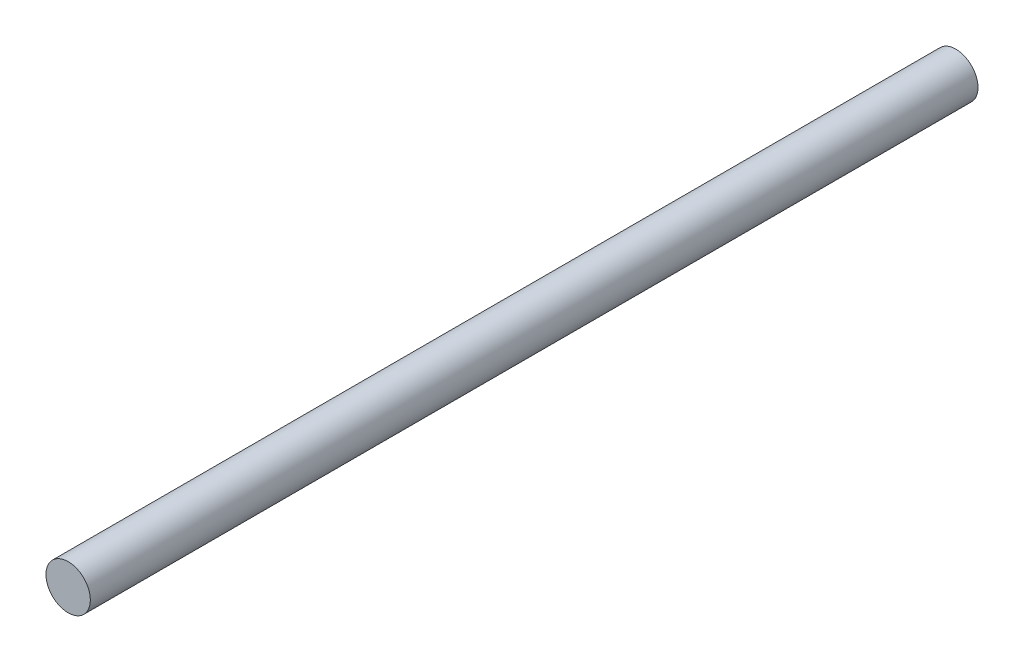
from build123d import *

# Parameters (mm, degrees)
CROQUIS1_R              = 6
SALIENTE_EXTRUIR1_DEPTH = 240


with BuildPart() as part:
    # Croquis1 → Saliente-Extruir1 (new body)
    with BuildSketch(Plane.XY):
        Circle(CROQUIS1_R)
    extrude(amount=SALIENTE_EXTRUIR1_DEPTH)


solid = part.part
